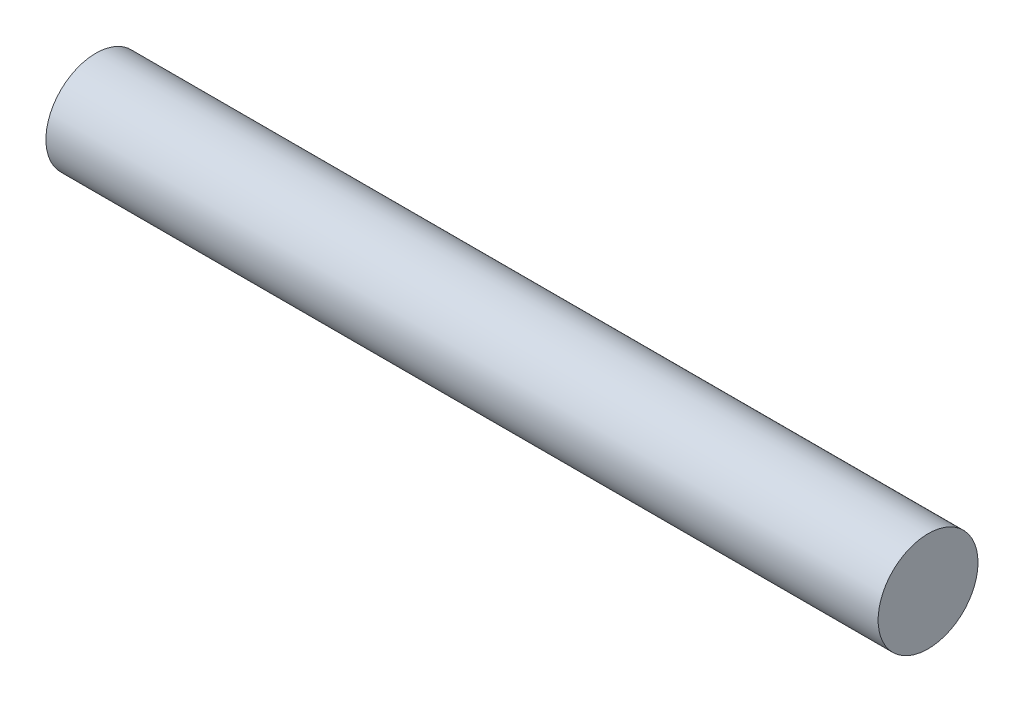
from build123d import *

# Parameters (mm, degrees)
SCHIZZO1_W = 25
SCHIZZO1_H = 1.5


with BuildPart() as part:
    # Schizzo1 → Rivoluzione1 (revolve)
    with BuildSketch(Plane.XY):
        with Locations((-12.5, 0.75)):
            Rectangle(SCHIZZO1_W, SCHIZZO1_H)
    revolve(axis=Axis((28.097332695, 0, 0), (-1, 0, 0)))


solid = part.part
